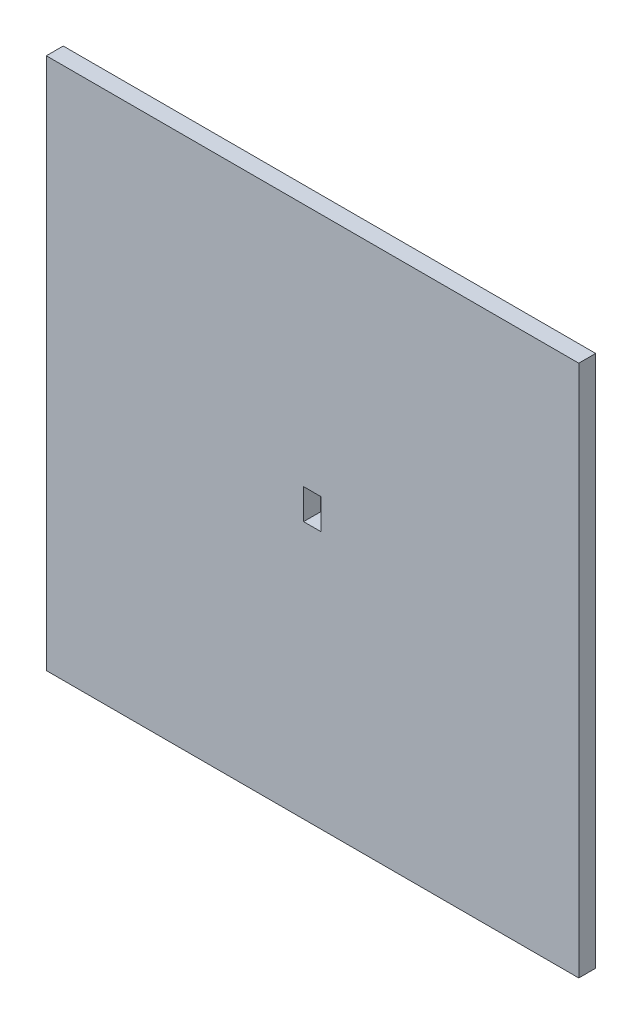
from build123d import *

# Parameters (mm, degrees)
SKETCH1_W           = 100
SKETCH1_H           = 100
BOSS_EXTRUDE1_DEPTH = 3.175
SKETCH3_W           = 3.3
SKETCH3_H           = 5.7
CUT_EXTRUDE1_DEPTH  = 4.175


with BuildPart() as part:
    # Sketch1 → Boss-Extrude1 (new body)
    with BuildSketch(Plane.XY):
        with Locations((50, 50)):
            Rectangle(SKETCH1_W, SKETCH1_H)
    extrude(amount=BOSS_EXTRUDE1_DEPTH)

    # Sketch3 → Cut-Extrude1 (cut, through all)
    with BuildSketch(Plane.XY.offset(3.175)):
        with Locations((49.966429689, 51.233570311)):
            Rectangle(SKETCH3_W, SKETCH3_H)
    extrude(amount=-CUT_EXTRUDE1_DEPTH, mode=Mode.SUBTRACT)


solid = part.part
